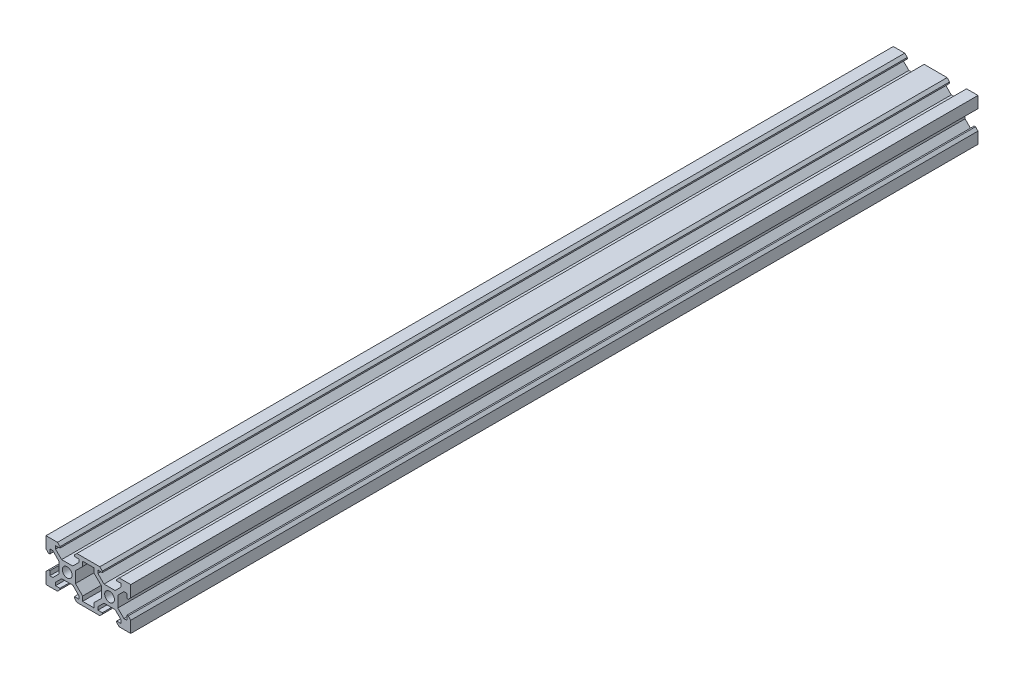
from build123d import *

# Parameters (mm, degrees)
SKETCH1_W           = 40
SKETCH1_H           = 20
BOSS_EXTRUDE1_DEPTH = 400
CUT_EXTRUDE3_DEPTH  = 401
CUT_EXTRUDE4_DEPTH  = 401
SKETCH6_R           = 2.3
CUT_EXTRUDE5_DEPTH  = 401


with BuildPart() as part:
    # Sketch1 → Boss-Extrude1 (new body)
    with BuildSketch(Plane.XY):
        with Locations((20, 10)):
            Rectangle(SKETCH1_W, SKETCH1_H)
    extrude(amount=-BOSS_EXTRUDE1_DEPTH)

    # Sketch2 → Cut-Extrude3 (cut, through all)
    with BuildSketch(Plane.XY):
        Polygon((14.58, 20), (13.395, 18.815), (13.395, 18.2), (15.5, 18.2), (15.5, 16.772792206), (12.627207794, 13.9), (7.372792206, 13.9), (4.5, 16.772792206), (4.5, 18.2), (6.605, 18.2), (6.605, 18.815), (5.42, 20), align=None)
        Polygon((1.185, 13.395), (0, 14.58), (0, 5.42), (1.185, 6.605), (1.8, 6.605), (1.8, 4.5), (3.227207794, 4.5), (6.1, 7.372792206), (6.1, 12.627207794), (3.227207794, 15.5), (1.8, 15.5), (1.8, 13.395), align=None)
        Polygon((38.2, 13.395), (38.815, 13.395), (40, 14.58), (40, 5.42), (38.815, 6.605), (38.2, 6.605), (38.2, 4.5), (36.772792206, 4.5), (33.9, 7.372792206), (33.9, 12.627207794), (36.772792206, 15.5), (38.2, 15.5), align=None)
        Polygon((33.395, 18.815), (34.58, 20), (25.42, 20), (26.605, 18.815), (26.605, 18.2), (24.5, 18.2), (24.5, 16.772792206), (27.372792206, 13.9), (32.627207794, 13.9), (35.5, 16.772792206), (35.5, 18.2), (33.395, 18.2), align=None)
        Polygon((33.395, 1.8), (33.395, 1.185), (34.58, 0), (25.42, 0), (26.605, 1.185), (26.605, 1.8), (24.5, 1.8), (24.5, 3.227207794), (27.372792206, 6.1), (32.627207794, 6.1), (35.5, 3.227207794), (35.5, 1.8), align=None)
        Polygon((6.605, 1.185), (5.42, 0), (14.58, 0), (13.395, 1.185), (13.395, 1.8), (15.5, 1.8), (15.5, 3.227207794), (12.627207794, 6.1), (7.372792206, 6.1), (4.5, 3.227207794), (4.5, 1.8), (6.605, 1.8), align=None)
    extrude(amount=-CUT_EXTRUDE3_DEPTH, mode=Mode.SUBTRACT)

    # Sketch5 → Cut-Extrude4 (cut, through all)
    with BuildSketch(Plane.XY):
        Polygon((17.3, 1.8), (22.7, 1.8), (22.7, 3.972792206), (26.1, 7.372792206), (26.1, 12.627207794), (22.7, 16.027207794), (22.7, 18.2), (17.3, 18.2), (17.3, 16.027207794), (13.9, 12.627207794), (13.9, 7.372792206), (17.3, 3.972792206), align=None)
    extrude(amount=-CUT_EXTRUDE4_DEPTH, mode=Mode.SUBTRACT)

    # Sketch6 → Cut-Extrude5 (cut, through all)
    with BuildSketch(Plane.XY):
        with Locations((10, 10)):
            Circle(SKETCH6_R)
        with Locations((30, 10)):
            Circle(SKETCH6_R)
    extrude(amount=-CUT_EXTRUDE5_DEPTH, mode=Mode.SUBTRACT)


solid = part.part
